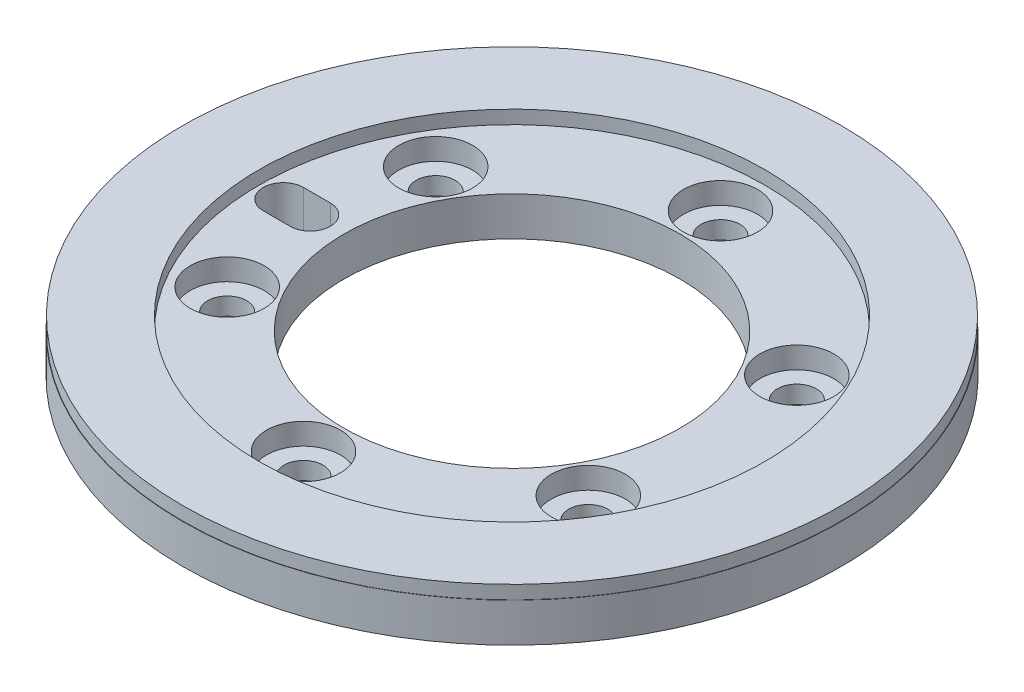
from build123d import *

# Parameters (mm, degrees)
SKETCH1_W                                            = 12
SKETCH1_H                                            = 2.9
CBORE_FOR_M2_5_HEX_SOCKET_HEAD_CAP_SCREW_D           = 2.9
CBORE_FOR_M2_5_HEX_SOCKET_HEAD_CAP_SCREW_CBORE_D     = 5.5
CBORE_FOR_M2_5_HEX_SOCKET_HEAD_CAP_SCREW_CBORE_DEPTH = 2.1
CIRPATTERN1_COUNT                                    = 6
CUT_EXTRUDE4_DEPTH                                   = 3.9
SKETCH5_R                                            = 24.475
SKETCH5_R_2                                          = 18.8
BOSS_EXTRUDE1_DEPTH                                  = 1


with BuildPart() as part:
    # Sketch1 → Revolve1 (revolve)
    with BuildSketch(Plane.XY):
        with Locations((-18.5, 1.45)):
            Rectangle(SKETCH1_W, SKETCH1_H)
    revolve(axis=Axis((0, -3.243860323, 0), (0, 1, 0)))

    # CBORE for M2.5 Hex Socket Head Cap Screw2 (through all)
    with Locations(Plane(origin=(0, 3.4, 0), x_dir=(-1, 0, 0), z_dir=(0, 1, 0))):
        with Locations((0, -15.5)):
            cbore_for_m2_5_hex_socket_head_cap_screw = CounterBoreHole(CBORE_FOR_M2_5_HEX_SOCKET_HEAD_CAP_SCREW_D / 2, CBORE_FOR_M2_5_HEX_SOCKET_HEAD_CAP_SCREW_CBORE_D / 2, CBORE_FOR_M2_5_HEX_SOCKET_HEAD_CAP_SCREW_CBORE_DEPTH)

    # CirPattern1: CBORE for M2.5 Hex Socket Head Cap Screw2 ×6 about axis
    cirpattern1_axis = Axis((0, 0, 0), (0, 1, 0))
    for i in range(1, CIRPATTERN1_COUNT):
        add(cbore_for_m2_5_hex_socket_head_cap_screw.rotate(cirpattern1_axis, i * 360 / CIRPATTERN1_COUNT), mode=Mode.SUBTRACT)

    # Sketch10 → Cut-Extrude4 (cut, through all)
    with BuildSketch(Plane(origin=(0, 2.9, 0), x_dir=(1, 0, 0), z_dir=(0, 1, 0))):
        with BuildLine():
            Line((-15, -1.5), (-17, -1.5))
            ThreePointArc((-17, -1.5), (-18.5, 0), (-17, 1.5))
            Line((-17, 1.5), (-15, 1.5))
            ThreePointArc((-15, 1.5), (-13.5, 0), (-15, -1.5))
        make_face()
    extrude(amount=-CUT_EXTRUDE4_DEPTH, mode=Mode.SUBTRACT)

    # Sketch5 → Boss-Extrude1 (add)
    with BuildSketch(Plane(origin=(0, 2.9, 0), x_dir=(1, 0, 0), z_dir=(0, 1, 0))):
        Circle(SKETCH5_R)
        Circle(SKETCH5_R_2, mode=Mode.SUBTRACT)
    extrude(amount=BOSS_EXTRUDE1_DEPTH)


solid = part.part
